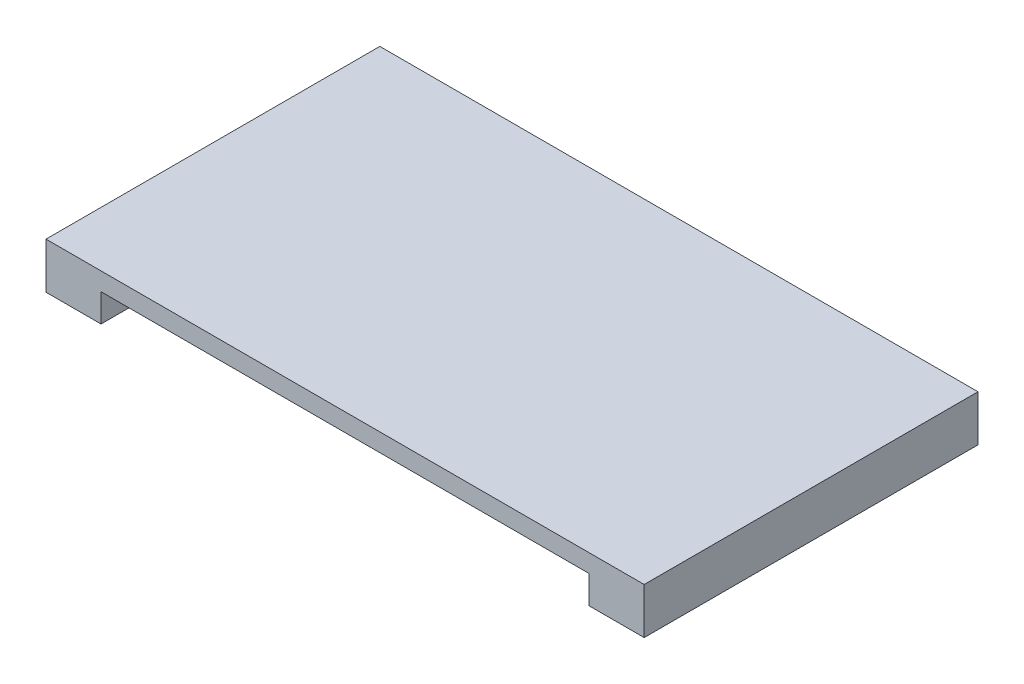
from build123d import *

# Parameters (mm, degrees)
SKETCH1_W           = 33.15
SKETCH1_H           = 18.5
BOSS_EXTRUDE1_DEPTH = 2.55
SKETCH2_W           = 27.05
SKETCH2_H           = 18.5
CUT_EXTRUDE1_DEPTH  = 1.55


with BuildPart() as part:
    # Sketch1 → Boss-Extrude1 (new body)
    with BuildSketch(Plane(origin=(0, 0, 0), x_dir=(1, 0, 0), z_dir=(0, 1, 0))):
        Rectangle(SKETCH1_W, SKETCH1_H)
    extrude(amount=BOSS_EXTRUDE1_DEPTH)

    # Sketch2 → Cut-Extrude1 (cut)
    with BuildSketch(Plane.XZ):
        Rectangle(SKETCH2_W, SKETCH2_H)
    extrude(amount=-CUT_EXTRUDE1_DEPTH, mode=Mode.SUBTRACT)


solid = part.part
